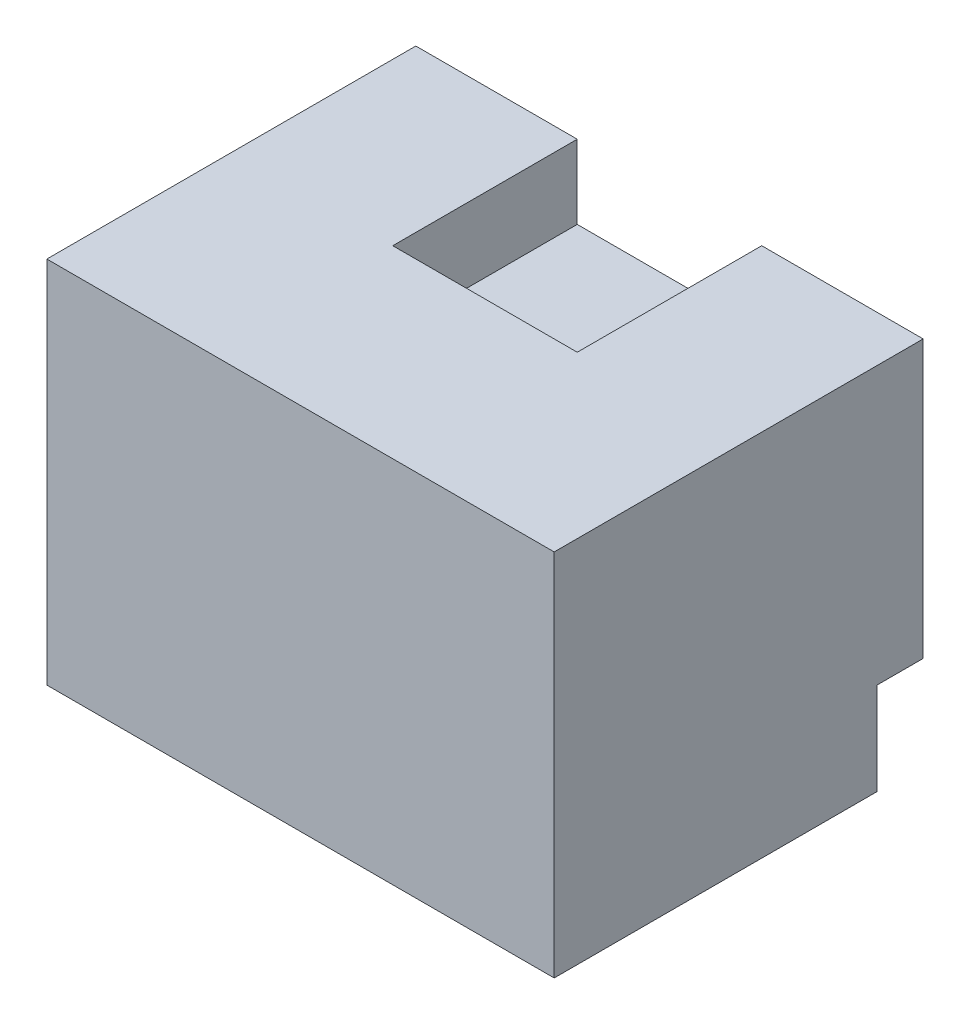
from build123d import *

# Parameters (mm, degrees)
BOSS_EXTRUDE1_DEPTH = 30
SKETCH2_W           = 20
SKETCH2_H           = 20
BOSS_EXTRUDE2_DEPTH = 22
SKETCH3_W           = 55
SKETCH3_H           = 35
BOSS_EXTRUDE3_DEPTH = 10


with BuildPart() as part:
    # Sketch1 → Boss-Extrude1 (new body)
    with BuildSketch(Plane(origin=(0, 0, 0), x_dir=(1, 0, 0), z_dir=(0, 1, 0))):
        Polygon((-10, 0), (-27.5, 0), (-27.5, -40), (27.5, -40), (27.5, 0), (10, 0), (10, -20), (-10, -20), align=None)
    extrude(amount=BOSS_EXTRUDE1_DEPTH)

    # Sketch2 → Boss-Extrude2 (add)
    with BuildSketch(Plane.XZ):
        with Locations((0, 10)):
            Rectangle(SKETCH2_W, SKETCH2_H)
    extrude(amount=-BOSS_EXTRUDE2_DEPTH)

    # Sketch3 → Boss-Extrude3 (add)
    with BuildSketch(Plane.XZ):
        with Locations((0, 22.5)):
            Rectangle(SKETCH3_W, SKETCH3_H)
    extrude(amount=BOSS_EXTRUDE3_DEPTH)


solid = part.part
